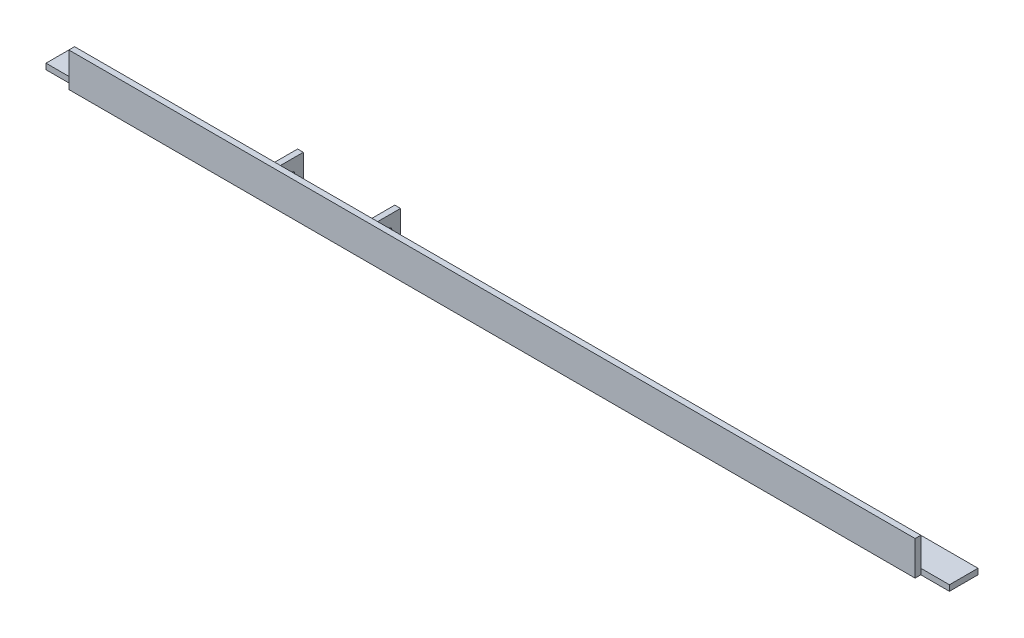
from build123d import *

# Parameters (mm, degrees)
BOSS_EXTRUDE1_DEPTH = 1003.3
BOSS_EXTRUDE2_DEPTH = 25.4
SKETCH3_W           = 101.6
SKETCH3_H           = 19.05
CUT_EXTRUDE1_DEPTH  = 7.35
SKETCH4_R           = 3.175
CUT_EXTRUDE2_DEPTH  = 756.65
SKETCH5_W           = 31.75
SKETCH5_H           = 38.1
CUT_EXTRUDE3_DEPTH  = 6.35


with BuildPart() as part:
    # Sketch1 → Boss-Extrude1 (new body)
    with BuildSketch(Plane(origin=(0, 0, 0), x_dir=(0, 0, -1), z_dir=(1, 0, 0))):
        Polygon((0, 0), (0, 31.75), (-6.35, 31.75), (-6.35, -6.35), (31.75, -6.35), (31.75, 0), align=None)
    extrude(amount=BOSS_EXTRUDE1_DEPTH)

    # Sketch2 → Boss-Extrude2 (add)
    with BuildSketch(Plane(origin=(0, 0, 0), x_dir=(1, 0, 0), z_dir=(0, 1, 0))):
        Polygon((247.65, 31.75), (254, 31.75), (254, 0), (222.25, 0), (222.25, 6.35), (247.65, 6.35), align=None)
        Polygon((387.35, 6.35), (387.35, 0), (355.6, 0), (355.6, 31.75), (361.95, 31.75), (361.95, 6.35), align=None)
    extrude(amount=BOSS_EXTRUDE2_DEPTH)

    # Sketch3 → Cut-Extrude1 (cut, through all)
    with BuildSketch(Plane(origin=(0, 0, 0), x_dir=(1, 0, 0), z_dir=(0, 1, 0))):
        with Locations((304.8, 22.225)):
            Rectangle(SKETCH3_W, SKETCH3_H)
    extrude(amount=-CUT_EXTRUDE1_DEPTH, mode=Mode.SUBTRACT)

    # Sketch4 → Cut-Extrude2 (cut, through all)
    with BuildSketch(Plane.ZY.offset(-247.65)):
        with Locations((-19.05, 9.525)):
            Circle(SKETCH4_R)
    extrude(amount=-CUT_EXTRUDE2_DEPTH, mode=Mode.SUBTRACT)

    # Sketch5 → Cut-Extrude3 (cut)
    with BuildSketch(Plane.XY.offset(6.35)):
        with Locations((15.875, 12.7)):
            Rectangle(SKETCH5_W, SKETCH5_H)
        with Locations((987.425, 12.7)):
            Rectangle(SKETCH5_W, SKETCH5_H)
    extrude(amount=-CUT_EXTRUDE3_DEPTH, mode=Mode.SUBTRACT)


solid = part.part
